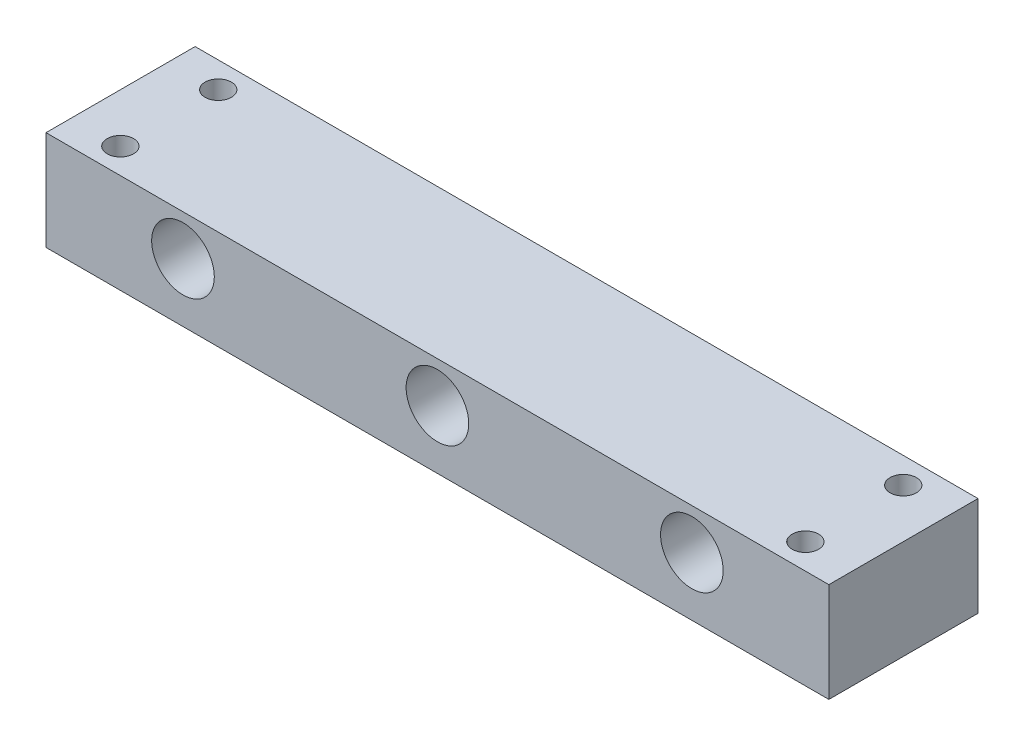
from build123d import *

# Parameters (mm, degrees)
SKETCH1_W           = 400
SKETCH1_H           = 76.2
BOSS_EXTRUDE1_DEPTH = 50.8
SKETCH3_R           = 6.75
CUT_EXTRUDE2_DEPTH  = 50.8
SKETCH5_R           = 16
CUT_EXTRUDE3_DEPTH  = 77.2


with BuildPart() as part:
    # Sketch1 → Boss-Extrude1 (new body)
    with BuildSketch(Plane(origin=(0, 0, 0), x_dir=(1, 0, 0), z_dir=(0, 1, 0))):
        with Locations((200, 38.1)):
            Rectangle(SKETCH1_W, SKETCH1_H)
    extrude(amount=BOSS_EXTRUDE1_DEPTH)

    # Sketch3 → Cut-Extrude2 (cut)
    with BuildSketch(Plane(origin=(0, 50.8, 0), x_dir=(1, 0, 0), z_dir=(0, 1, 0))):
        with Locations((25, 63)):
            Circle(SKETCH3_R)
        with Locations((25, 13)):
            Circle(SKETCH3_R)
        with Locations((375, 63)):
            Circle(SKETCH3_R)
        with Locations((375, 13)):
            Circle(SKETCH3_R)
    extrude(amount=-CUT_EXTRUDE2_DEPTH, mode=Mode.SUBTRACT)

    # Sketch5 → Cut-Extrude3 (cut, through all)
    with BuildSketch(Plane.XY):
        with Locations((200, 30)):
            Circle(SKETCH5_R)
        with Locations((70, 30)):
            Circle(SKETCH5_R)
        with Locations((330, 30)):
            Circle(SKETCH5_R)
    extrude(amount=-CUT_EXTRUDE3_DEPTH, mode=Mode.SUBTRACT)


solid = part.part
